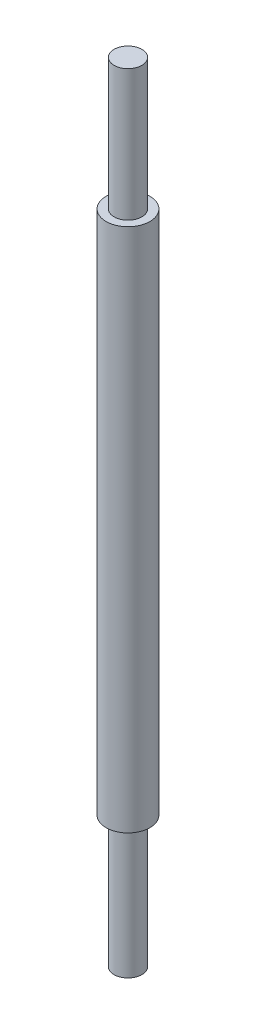
from build123d import *

# Parameters (mm, degrees)
SKETCH1_R           = 3.175
BOSS_EXTRUDE2_DEPTH = 90
SKETCH1_4_R         = 5
SKETCH1_4_R_2       = 3.175
BOSS_EXTRUDE3_DEPTH = 60


with BuildPart() as part:
    # Sketch1 → Boss-Extrude2 (new, symmetric)
    with BuildSketch(Plane(origin=(0, 0, 0), x_dir=(1, 0, 0), z_dir=(0, 1, 0))):
        Circle(SKETCH1_R)
    extrude(amount=BOSS_EXTRUDE2_DEPTH, both=True)

    # Sketch1_4 → Boss-Extrude3 (add, symmetric)
    with BuildSketch(Plane(origin=(0, 0, 0), x_dir=(1, 0, 0), z_dir=(0, 1, 0))):
        Circle(SKETCH1_4_R)
        Circle(SKETCH1_4_R_2, mode=Mode.SUBTRACT)
    extrude(amount=BOSS_EXTRUDE3_DEPTH, both=True)


solid = part.part
